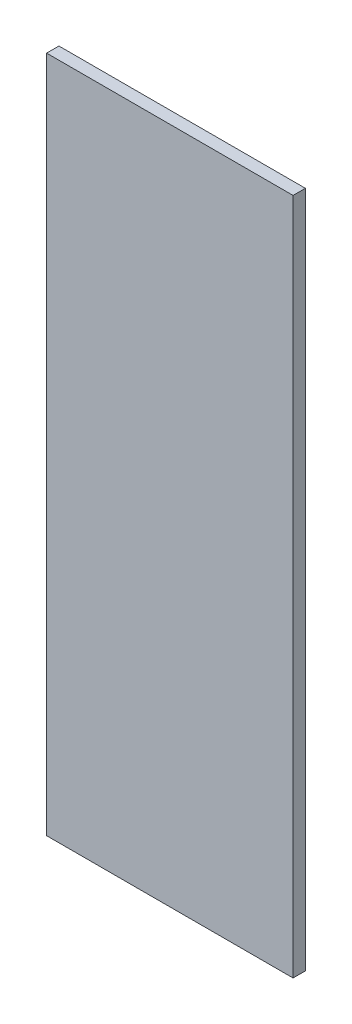
from build123d import *

# Parameters (mm, degrees)
SKETCH_1_W      = 100
SKETCH_1_H      = 275
EXTRUDE_1_DEPTH = 5


with BuildPart() as part:
    # 草图1 → 凸台-拉伸1 (new body)
    with BuildSketch(Plane.XY):
        Rectangle(SKETCH_1_W, SKETCH_1_H)
    extrude(amount=EXTRUDE_1_DEPTH)


solid = part.part
